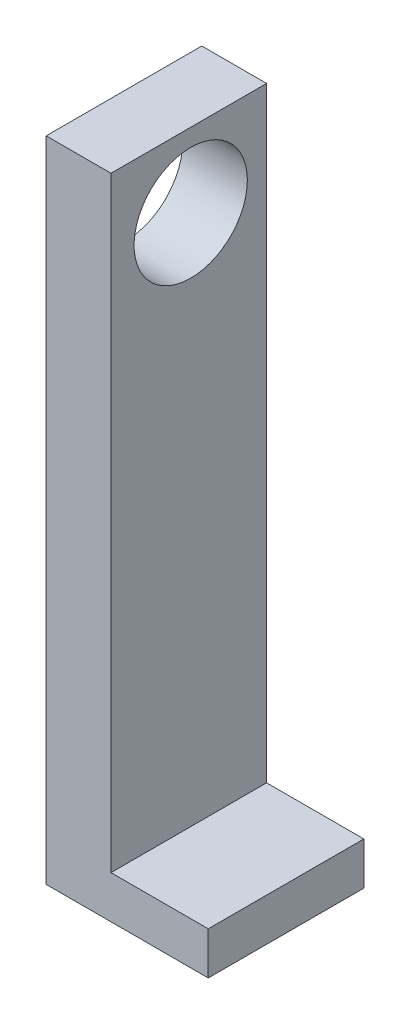
from build123d import *

# Parameters (mm, degrees)
SKETCH1_W           = 24
SKETCH1_H           = 100
SKETCH1_R           = 8.735
BOSS_EXTRUDE1_DEPTH = 10
SKETCH2_W           = 24
SKETCH2_H           = 6.573473922
BOSS_EXTRUDE2_DEPTH = 15


with BuildPart() as part:
    # Sketch1 → Boss-Extrude1 (new body)
    with BuildSketch(Plane(origin=(0, 0, 0), x_dir=(0, 0, -1), z_dir=(1, 0, 0))):
        with Locations((-0.298142376, -38.573473922)):
            Rectangle(SKETCH1_W, SKETCH1_H)
        Circle(SKETCH1_R, mode=Mode.SUBTRACT)
    extrude(amount=BOSS_EXTRUDE1_DEPTH)

    # Sketch2 → Boss-Extrude2 (add)
    with BuildSketch(Plane(origin=(10, 0, 0), x_dir=(0, 0, -1), z_dir=(1, 0, 0))):
        with Locations((-0.298142376, -85.286736961)):
            Rectangle(SKETCH2_W, SKETCH2_H)
    extrude(amount=BOSS_EXTRUDE2_DEPTH)


solid = part.part
